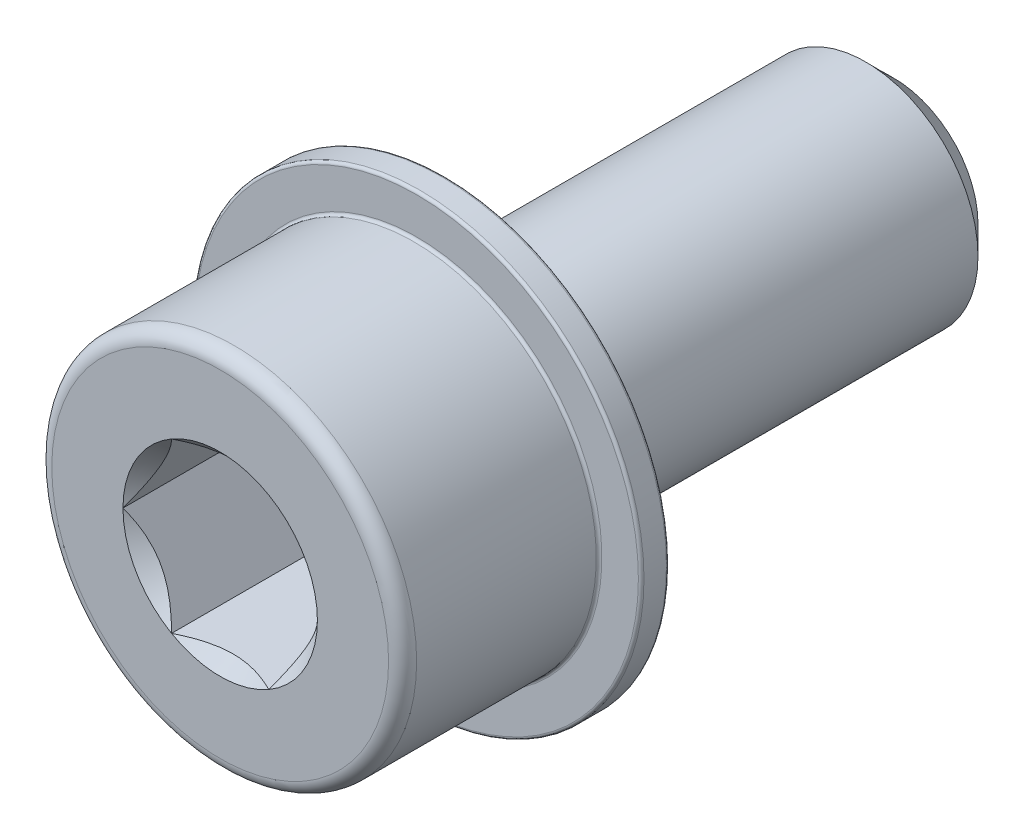
from build123d import *

# Parameters (mm, degrees)
SCHIZZO1_R                   = 4
ESTRUSIONE_ESTRUSIONE1_DEPTH = 16
SMUSSO1_SIZE                 = 1
SCHIZZO6_R                   = 6.5
ESTRUSIONE_ESTRUSIONE3_DEPTH = 8
TAGLIO_ESTRUSIONE3_DEPTH     = 6
SCHIZZO8_R                   = 3.464101615
TAGLIO_ESTRUSIONE4_DEPTH     = 1
TAGLIO_ESTRUSIONE4_TAPER     = 45
RACCORDO1_R                  = 0.5
SCHIZZO9_R                   = 8
SCHIZZO9_R_2                 = 6.5
ESTRUSIONE_ESTRUSIONE4_DEPTH = 1
RACCORDO2_R                  = 0.1


with BuildPart() as part:
    # Schizzo1 → Estrusione-Estrusione1 (new body)
    with BuildSketch(Plane.XY):
        Circle(SCHIZZO1_R)
    extrude(amount=ESTRUSIONE_ESTRUSIONE1_DEPTH)

    # Smusso1
    smusso1_edges = [part.edges().sort_by_distance(p)[0] for p in [
        (-4, 0, 0),
    ]]
    chamfer(smusso1_edges, length=SMUSSO1_SIZE)

    # Schizzo6 → Estrusione-Estrusione3 (add)
    with BuildSketch(Plane.XY.offset(16)):
        Circle(SCHIZZO6_R)
    extrude(amount=ESTRUSIONE_ESTRUSIONE3_DEPTH)

    # Schizzo7 → Taglio-Estrusione3 (cut)
    with BuildSketch(Plane.XY.offset(24)):
        Polygon((1.732050808, 3), (-1.732050808, 3), (-3.464101615, 0), (-1.732050808, -3), (1.732050808, -3), (3.464101615, 0), align=None)
    extrude(amount=-TAGLIO_ESTRUSIONE3_DEPTH, mode=Mode.SUBTRACT)

    # Schizzo8 → Taglio-Estrusione4 (cut)
    with BuildSketch(Plane.XY.offset(24)):
        Circle(SCHIZZO8_R)
    extrude(amount=-TAGLIO_ESTRUSIONE4_DEPTH, taper=TAGLIO_ESTRUSIONE4_TAPER, mode=Mode.SUBTRACT)

    # Raccordo1
    raccordo1_edges = [part.edges().sort_by_distance(p)[0] for p in [
        (-6.5, 0, 24),
    ]]
    fillet(raccordo1_edges, radius=RACCORDO1_R)

    # Schizzo9 → Estrusione-Estrusione4 (add)
    with BuildSketch(Plane(origin=(0, 0, 16), x_dir=(-1, 0, 0), z_dir=(0, 0, -1))):
        Circle(SCHIZZO9_R)
        Circle(SCHIZZO9_R_2, mode=Mode.SUBTRACT)
    extrude(amount=-ESTRUSIONE_ESTRUSIONE4_DEPTH)

    # Raccordo2
    raccordo2_edges = [part.edges().sort_by_distance(p)[0] for p in [
        (-6.5, 0, 17),
        (8, 0, 17),
        (8, 0, 16),
    ]]
    fillet(raccordo2_edges, radius=RACCORDO2_R)


solid = part.part
